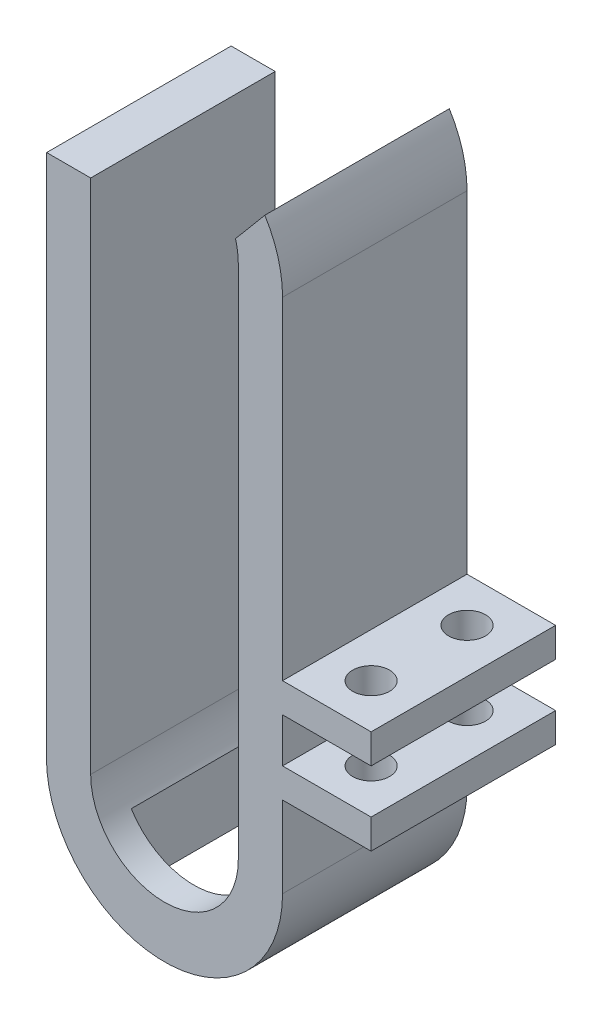
from build123d import *

# Parameters (mm, degrees)
BOSS_EXTRUDE1_DEPTH     = 12.5
SKETCH2_W               = 12.5
SKETCH2_H               = 2
BOSS_EXTRUDE2_DEPTH     = 6
SKETCH3_R               = 1.25
CUT_EXTRUDE1_DEPTH      = 32.713927878
CUT_EXTRUDE1_DEPTH_BACK = 16.499999831
SKETCH5_W               = 8.5
SKETCH5_H               = 8.5
CUT_EXTRUDE2_DEPTH      = 26.999999831


with BuildPart() as part:
    # Sketch1 → Boss-Extrude1 (new body)
    with BuildSketch(Plane.XY):
        with BuildLine():
            ThreePointArc((8, 17), (7.694207367, 19.190701486), (6.80020675, 21.213927878))
            Line((6.80020675, 21.213927878), (4.814885895, 18.847914617))
            ThreePointArc((4.814885895, 18.847914617), (4.953505298, 18.180283222), (5, 17.5))
            Line((5, 17.5), (5, -17.5))
            ThreePointArc((5, -17.5), (0, -22.5), (-5, -17.5))
            Line((-5, -17.5), (-5, 17.5))
            Line((-5, 17.5), (-7.984359711, 17.5))
            ThreePointArc((-7.984359711, 17.5), (-7.996088972, 17.250122279), (-8, 17))
            Line((-8, 17), (-8, -17.999999662))
            ThreePointArc((-8, -17.999999662), (-1.69e-07, -25.999999831), (8, -18))
            Line((8, -18), (8, 17))
        make_face()
    extrude(amount=BOSS_EXTRUDE1_DEPTH)

    # Sketch2 → Boss-Extrude2 (add)
    with BuildSketch(Plane(origin=(8, 0, 0), x_dir=(0, 0, -1), z_dir=(1, 0, 0))):
        with Locations((-6.25, -11.5)):
            Rectangle(SKETCH2_W, SKETCH2_H)
        with Locations((-6.25, -6.5)):
            Rectangle(SKETCH2_W, SKETCH2_H)
    extrude(amount=BOSS_EXTRUDE2_DEPTH)

    # Sketch3 → Cut-Extrude1 (cut, two sides)
    with BuildSketch(Plane(origin=(0, -10.5, 0), x_dir=(1, 0, 0), z_dir=(0, 1, 0))) as cut_extrude1_sk:
        with Locations((11, -3)):
            Circle(SKETCH3_R)
        with Locations((11, -9.5)):
            Circle(SKETCH3_R)
    extrude(amount=CUT_EXTRUDE1_DEPTH, mode=Mode.SUBTRACT)
    extrude(cut_extrude1_sk.sketch, amount=-CUT_EXTRUDE1_DEPTH_BACK, mode=Mode.SUBTRACT)

    # Sketch5 → Cut-Extrude2 (cut, through all)
    with BuildSketch(Plane(origin=(0, 0, 0), x_dir=(1, 0, 0), z_dir=(0, 1, 0))):
        with Locations((0, -6.25)):
            Rectangle(SKETCH5_W, SKETCH5_H)
    extrude(amount=-CUT_EXTRUDE2_DEPTH, mode=Mode.SUBTRACT)


solid = part.part
